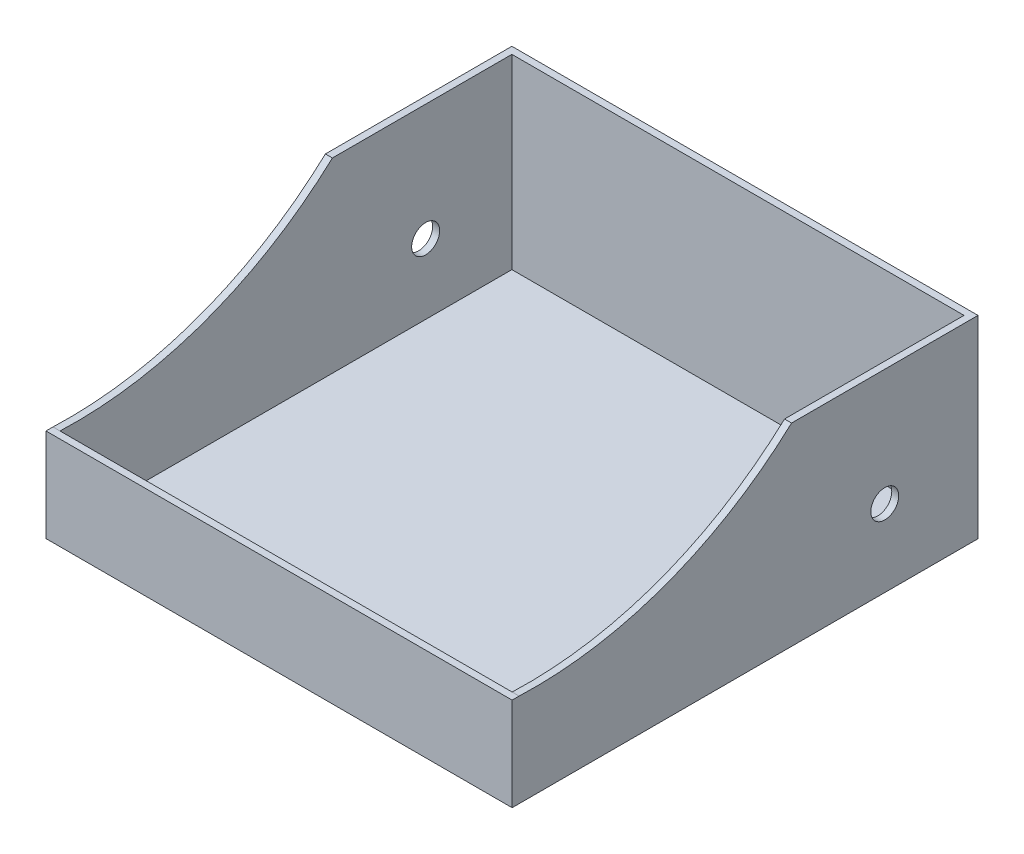
from build123d import *

# Parameters (mm, degrees)
SKETCH3_W            = 200
SKETCH3_H            = 199.898
BOSS_EXTRUDE2_DEPTH  = 3
SKETCH9_W            = 3
SKETCH9_H            = 80
BOSS_EXTRUDE3_DEPTH  = 80
SKETCH10_W           = 3
SKETCH10_H           = 80
BOSS_EXTRUDE4_DEPTH  = 80
SKETCH11_W           = 200
SKETCH11_H           = 3
BOSS_EXTRUDE6_DEPTH  = 40
SKETCH23_R           = 6
CUT_EXTRUDE5_DEPTH   = 228.956
BOSS_EXTRUDE8_DEPTH  = 3
BOSS_EXTRUDE9_DEPTH  = 3
SKETCH30_R           = 6
CUT_EXTRUDE6_DEPTH   = 225.25
SKETCH32_W           = 200
SKETCH32_H           = 3
BOSS_EXTRUDE12_DEPTH = 83


with BuildPart() as part:
    # Sketch3 → Boss-Extrude2 (new body)
    with BuildSketch(Plane(origin=(0, 0, 0), x_dir=(1, 0, 0), z_dir=(0, 1, 0))):
        Rectangle(SKETCH3_W, SKETCH3_H)
    extrude(amount=BOSS_EXTRUDE2_DEPTH)

    # Sketch9 → Boss-Extrude3 (add)
    with BuildSketch(Plane(origin=(0, 3, 0), x_dir=(1, 0, 0), z_dir=(0, 1, 0))):
        with Locations((-98.5, 59.949)):
            Rectangle(SKETCH9_W, SKETCH9_H)
    extrude(amount=BOSS_EXTRUDE3_DEPTH)

    # Sketch10 → Boss-Extrude4 (add)
    with BuildSketch(Plane(origin=(0, 3, 0), x_dir=(1, 0, 0), z_dir=(0, 1, 0))):
        with Locations((98.5, 59.949)):
            Rectangle(SKETCH10_W, SKETCH10_H)
    extrude(amount=BOSS_EXTRUDE4_DEPTH)

    # Sketch11 → Boss-Extrude6 (add)
    with BuildSketch(Plane(origin=(0, 0, 0), x_dir=(1, 0, 0), z_dir=(0, 1, 0))):
        with Locations((0, -98.449)):
            Rectangle(SKETCH11_W, SKETCH11_H)
    extrude(amount=BOSS_EXTRUDE6_DEPTH)

    # Sketch23 → Cut-Extrude5 (cut)
    with BuildSketch(Plane.ZY.offset(100)):
        with Locations((-59.949, 33)):
            Circle(SKETCH23_R)
    extrude(amount=-CUT_EXTRUDE5_DEPTH, mode=Mode.SUBTRACT)

    # Sketch26 → Boss-Extrude8 (add)
    with BuildSketch(Plane.ZY.offset(100)):
        with BuildLine():
            Line((99.949, 0), (99.949, 40))
            Line((99.949, 40), (96.949, 40))
            ThreePointArc((96.949, 40), (34.223384101, 49.873771039), (-19.949, 83))
            Line((-19.949, 83), (-99.949, 83))
            Line((-99.949, 83), (-99.949, 0))
            Line((-99.949, 0), (99.949, 0))
        make_face()
    extrude(amount=-BOSS_EXTRUDE8_DEPTH)

    # Sketch29 → Boss-Extrude9 (add)
    with BuildSketch(Plane(origin=(100, 0, 0), x_dir=(0, 0, -1), z_dir=(1, 0, 0))):
        with BuildLine():
            ThreePointArc((19.949, 83), (-34.223384101, 49.873771039), (-96.949, 40))
            Line((-96.949, 40), (-96.949, 3))
            Line((-96.949, 3), (19.949, 3))
            Line((19.949, 3), (19.949, 83))
        make_face()
    extrude(amount=-BOSS_EXTRUDE9_DEPTH)

    # Sketch30 → Cut-Extrude6 (cut)
    with BuildSketch(Plane(origin=(100, 0, 0), x_dir=(0, 0, -1), z_dir=(1, 0, 0))):
        with Locations((59.949, 33)):
            Circle(SKETCH30_R)
    extrude(amount=-CUT_EXTRUDE6_DEPTH, mode=Mode.SUBTRACT)

    # Sketch32 → Boss-Extrude12 (add)
    with BuildSketch(Plane(origin=(0, 0, 0), x_dir=(1, 0, 0), z_dir=(0, 1, 0))):
        with Locations((0, 98.449)):
            Rectangle(SKETCH32_W, SKETCH32_H)
    extrude(amount=BOSS_EXTRUDE12_DEPTH)


solid = part.part
